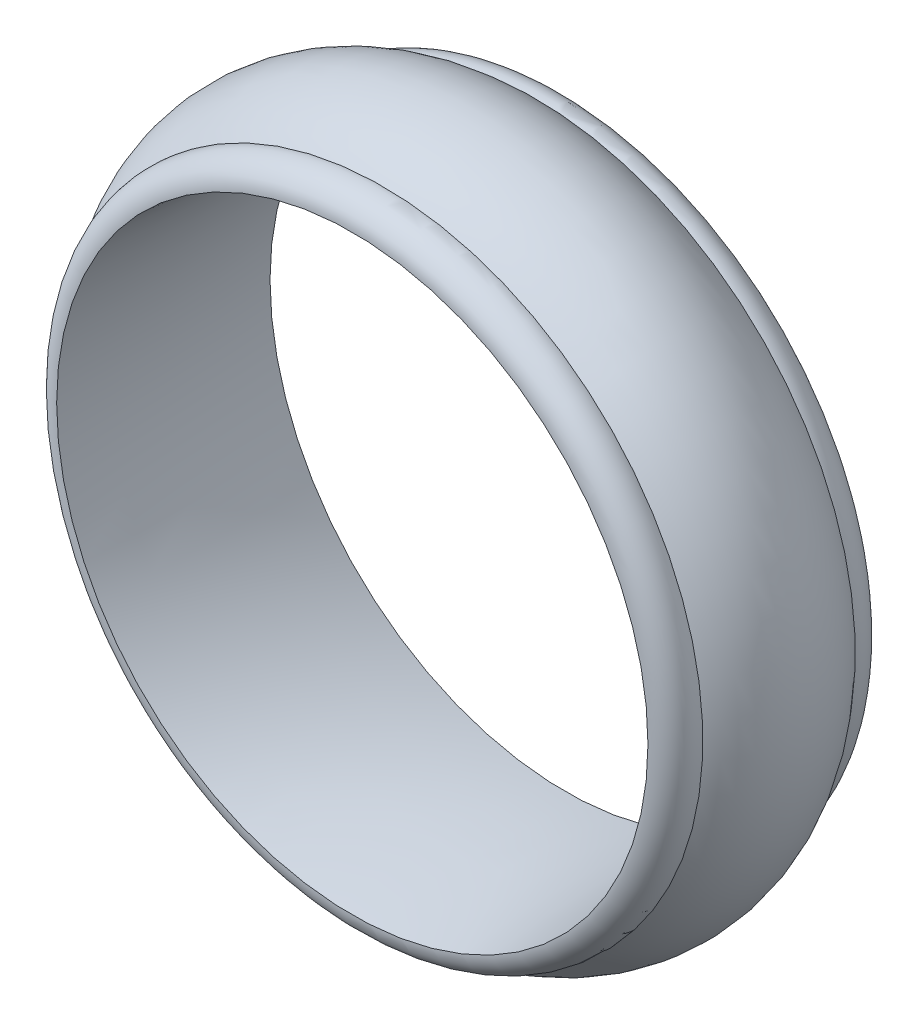
from build123d import *


with BuildPart() as part:
    # Эскиз1 → Повернуть1 (revolve)
    with BuildSketch(Plane(origin=(0, 0, 0), x_dir=(0, 0, -1), z_dir=(1, 0, 0))):
        with BuildLine():
            ThreePointArc((-3.5, 9.7), (-3.192249939, 10.340312424), (-2.5, 10.5))
            ThreePointArc((-2.5, 10.5), (0, 11.5), (2.5, 10.5))
            ThreePointArc((2.5, 10.5), (3.192249939, 10.340312424), (3.5, 9.7))
            ThreePointArc((3.5, 9.7), (0, 9.5), (-3.5, 9.7))
        make_face()
    revolve(axis=Axis((0, 0, 0), (0, 0, 1)))


solid = part.part
